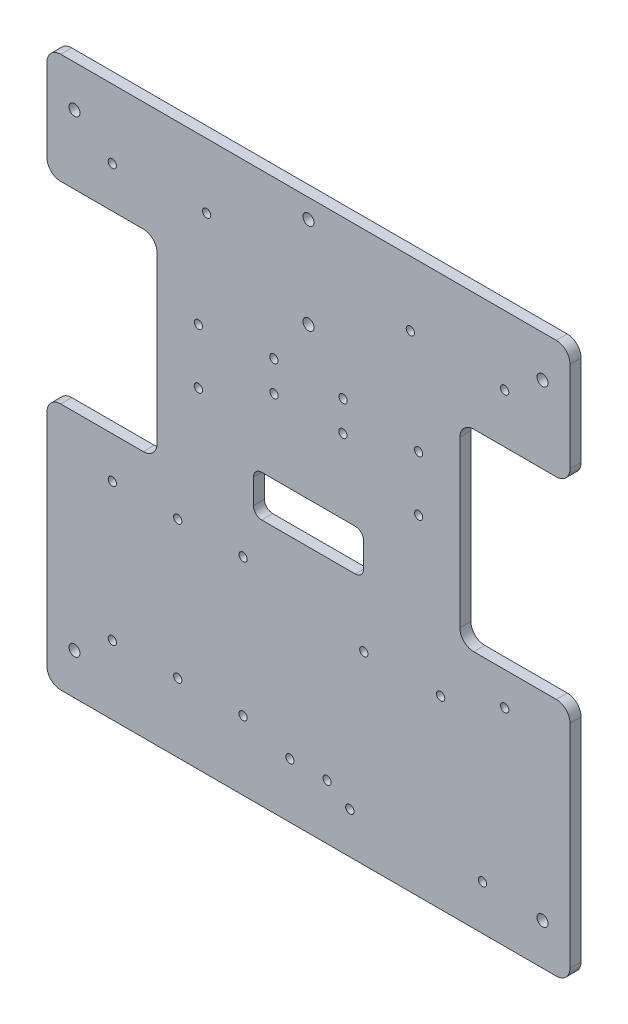
from build123d import *

# Parameters (mm, degrees)
BOSS_EXTRUDE1_DEPTH = 4
SKETCH2_R           = 2
SKETCH2_R_2         = 1.5
CUT_EXTRUDE1_DEPTH  = 20
SKETCH3_R           = 1.5
CUT_EXTRUDE2_DEPTH  = 10
SKETCH5_R           = 1.5
SKETCH5_R_2         = 2
CUT_EXTRUDE3_DEPTH  = 5
SKETCH7_R           = 1.5
CUT_EXTRUDE4_DEPTH  = 10


with BuildPart() as part:
    # Sketch1 → Boss-Extrude1 (new body)
    with BuildSketch(Plane.XY):
        with BuildLine():
            Line((-95, -115), (-95, -195))
            ThreePointArc((-95, -195), (-93.535533906, -198.535533906), (-90, -200))
            Line((-90, -200), (90, -200))
            ThreePointArc((90, -200), (93.535533906, -198.535533906), (95, -195))
            Line((95, -195), (95, -117.93976744))
            ThreePointArc((95, -117.93976744), (93.535533906, -114.404233535), (90, -112.93976744))
            Line((90, -112.93976744), (60, -112.93976744))
            ThreePointArc((60, -112.93976744), (56.464466094, -111.475301346), (55, -107.93976744))
            Line((55, -107.93976744), (55, -47.93976744))
            ThreePointArc((55, -47.93976744), (56.464466094, -44.404233535), (60, -42.93976744))
            Line((60, -42.93976744), (90, -42.93976744))
            ThreePointArc((90, -42.93976744), (93.535533906, -41.475301346), (95, -37.93976744))
            Line((95, -37.93976744), (95, -5))
            ThreePointArc((95, -5), (93.535533906, -1.464466094), (90, 0))
            Line((90, 0), (-90, 0))
            ThreePointArc((-90, 0), (-93.535533906, -1.464466094), (-95, -5))
            Line((-95, -5), (-95, -35))
            ThreePointArc((-95, -35), (-93.535533906, -38.535533906), (-90, -40))
            Line((-90, -40), (-60, -40))
            ThreePointArc((-60, -40), (-56.464466094, -41.464466094), (-55, -45))
            Line((-55, -45), (-55, -105))
            ThreePointArc((-55, -105), (-56.464466094, -108.535533906), (-60, -110))
            Line((-60, -110), (-90, -110))
            ThreePointArc((-90, -110), (-93.535533906, -111.464466094), (-95, -115))
        make_face()
    extrude(amount=BOSS_EXTRUDE1_DEPTH)

    # Sketch2 → Cut-Extrude1 (cut)
    with BuildSketch(Plane.XY.offset(4)):
        with Locations((-85, -185)):
            Circle(SKETCH2_R)
        with Locations((-85, -15)):
            Circle(SKETCH2_R)
        with Locations((85, -15)):
            Circle(SKETCH2_R)
        with Locations((85, -185)):
            Circle(SKETCH2_R)
        with Locations((-6.765, -180)):
            Circle(SKETCH2_R_2)
        with Locations((6.765, -180)):
            Circle(SKETCH2_R_2)
    extrude(amount=-CUT_EXTRUDE1_DEPTH, mode=Mode.SUBTRACT)

    # Sketch3 → Cut-Extrude2 (cut)
    with BuildSketch(Plane.XY.offset(4)):
        with Locations((-71.25, -25)):
            Circle(SKETCH3_R)
        with Locations((-71.25, -75)):
            Circle(SKETCH3_R)
        with Locations((-71.25, -175)):
            Circle(SKETCH3_R)
        with Locations((-71.25, -125)):
            Circle(SKETCH3_R)
        with Locations((71.25, -125)):
            Circle(SKETCH3_R)
        with Locations((71.25, -75)):
            Circle(SKETCH3_R)
        with Locations((71.25, -25)):
            Circle(SKETCH3_R)
        with Locations((-23.75, -125)):
            Circle(SKETCH3_R)
        with Locations((-23.75, -175)):
            Circle(SKETCH3_R)
        with Locations((-47.5, -125)):
            Circle(SKETCH3_R)
        with Locations((-47.5, -175)):
            Circle(SKETCH3_R)
    extrude(amount=-CUT_EXTRUDE2_DEPTH, mode=Mode.SUBTRACT)

    # Sketch5 → Cut-Extrude3 (cut, through all)
    with BuildSketch(Plane.XY.offset(4)):
        with Locations((-40, -60)):
            Circle(SKETCH5_R)
        with Locations((-40, -80)):
            Circle(SKETCH5_R)
        with Locations((40, -80)):
            Circle(SKETCH5_R)
        with Locations((40, -60)):
            Circle(SKETCH5_R)
        with Locations((20.1, -132.9)):
            Circle(SKETCH5_R)
        with Locations((15, -185)):
            Circle(SKETCH5_R)
        with Locations((63.2, -183.7)):
            Circle(SKETCH5_R)
        with Locations((48, -132.9)):
            Circle(SKETCH5_R)
        with Locations((0, -7)):
            Circle(SKETCH5_R_2)
        with Locations((0, -40)):
            Circle(SKETCH5_R_2)
        with Locations((-37, -23.5)):
            Circle(SKETCH5_R)
        with Locations((37, -23.5)):
            Circle(SKETCH5_R)
    extrude(amount=-CUT_EXTRUDE3_DEPTH, mode=Mode.SUBTRACT)

    # Sketch7 → Cut-Extrude4 (cut)
    with BuildSketch(Plane(origin=(0, 0, 0), x_dir=(-1, 0, 0), z_dir=(0, 0, -1))):
        with Locations((12.568709429, -57.035989116)):
            Circle(SKETCH7_R)
        with Locations((12.5, -68.035774524)):
            Circle(SKETCH7_R)
        with Locations((-12.5, -68.035774524)):
            Circle(SKETCH7_R)
        with Locations((-12.568709429, -57.035989116)):
            Circle(SKETCH7_R)
        with BuildLine():
            Line((17, -110), (-17, -110))
            ThreePointArc((-17, -110), (-19.121320344, -109.121320344), (-20, -107))
            Line((-20, -107), (-20, -98))
            ThreePointArc((-20, -98), (-19.121320344, -95.878679656), (-17, -95))
            Line((-17, -95), (17, -95))
            ThreePointArc((17, -95), (19.121320344, -95.878679656), (20, -98))
            Line((20, -98), (20, -107))
            ThreePointArc((20, -107), (19.121320344, -109.121320344), (17, -110))
        make_face()
    extrude(amount=-CUT_EXTRUDE4_DEPTH, mode=Mode.SUBTRACT)


solid = part.part
